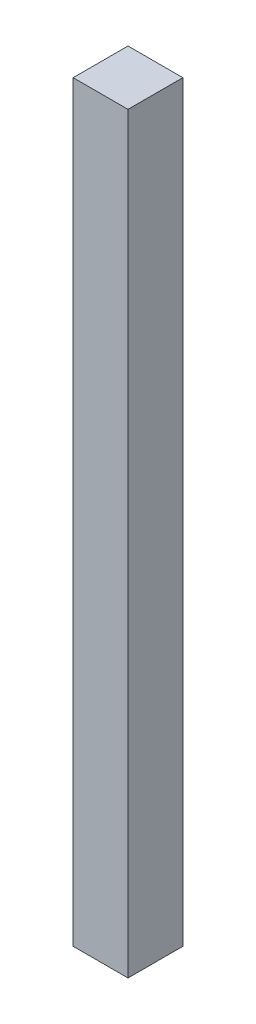
from build123d import *

# Parameters (mm, degrees)
SKETCH2_W           = 88.9
SKETCH2_H           = 88.9
BOSS_EXTRUDE1_DEPTH = 1219.2


with BuildPart() as part:
    # Sketch2 → Boss-Extrude1 (new body)
    with BuildSketch(Plane(origin=(0, 0, 0), x_dir=(1, 0, 0), z_dir=(0, 1, 0))):
        with Locations((-44.45, -44.45)):
            Rectangle(SKETCH2_W, SKETCH2_H)
    extrude(amount=-BOSS_EXTRUDE1_DEPTH)


solid = part.part
